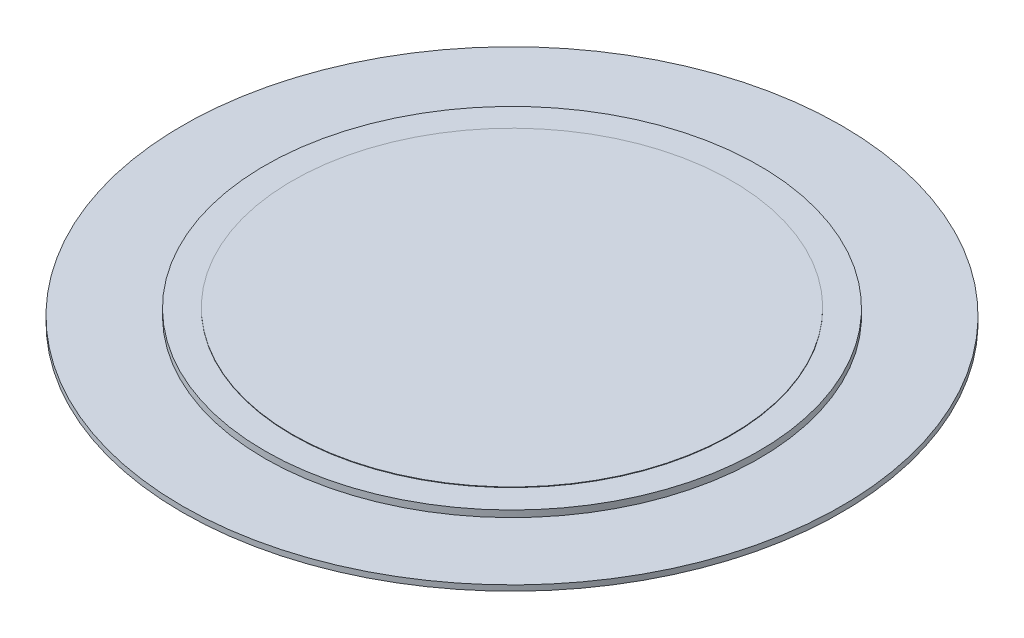
from build123d import *

# Parameters (mm, degrees)
SKETCH_1_R      = 6
EXTRUDE_1_DEPTH = 0.1
SKETCH_2_R      = 4.5
EXTRUDE_2_DEPTH = 0.12
SKETCH_3_R      = 4
EXTRUDE_3_DEPTH = 0.01


with BuildPart() as part:
    # 草图1 → 凸台-拉伸1 (new body)
    with BuildSketch(Plane(origin=(0, 0, 0), x_dir=(1, 0, 0), z_dir=(0, 1, 0))):
        Circle(SKETCH_1_R)
    extrude(amount=EXTRUDE_1_DEPTH)

    # 草图2 → 凸台-拉伸2 (add)
    with BuildSketch(Plane(origin=(0, 0.1, 0), x_dir=(1, 0, 0), z_dir=(0, 1, 0))):
        Circle(SKETCH_2_R)
    extrude(amount=EXTRUDE_2_DEPTH)

    # 草图3 → 凸台-拉伸3 (add)
    with BuildSketch(Plane(origin=(0, 0.22, 0), x_dir=(1, 0, 0), z_dir=(0, 1, 0))):
        Circle(SKETCH_3_R)
    extrude(amount=EXTRUDE_3_DEPTH)


solid = part.part
